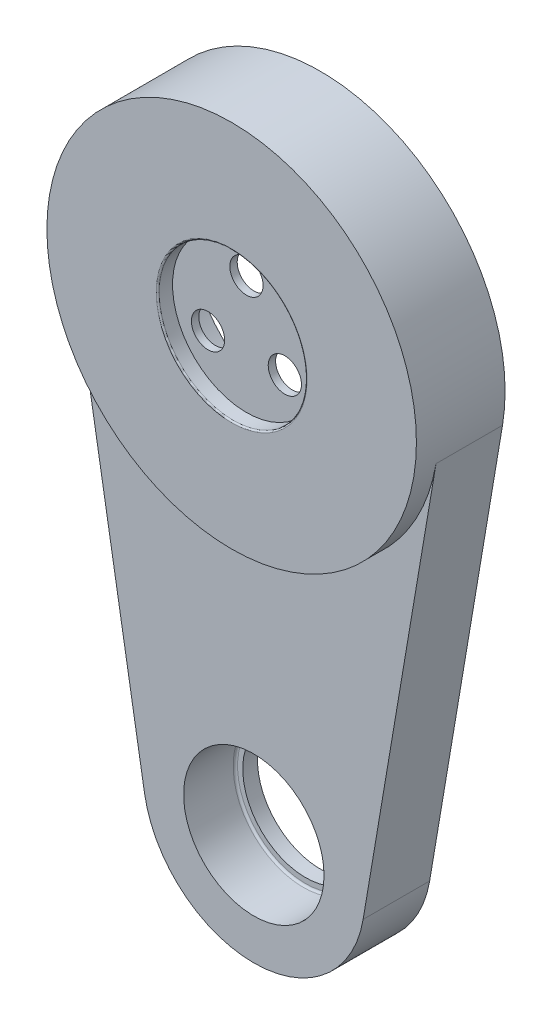
from build123d import *

# Parameters (mm, degrees)
SKETCH_2_R                   = 25
EXTRUDE_2_DEPTH              = 2
SKETCH_22_R                  = 10
CUT_EXTRUDE_1_DEPTH          = 2
FILLET_4_R                   = 0.2
SKETCH_54_R                  = 25
EXTRUDE_6_DEPTH              = 10
SKETCH_55_R                  = 18.5
CUT_EXTRUDE_2_DEPTH          = 8
HOLE_WIZARD_M4_1_D           = 4.5
HOLE_WIZARD_M4_1_CBORE_D     = 8
HOLE_WIZARD_M4_1_CBORE_DEPTH = 1
PATTERN_CIRCULAR_1_COUNT     = 3
SKETCH_59_R                  = 18.5
SKETCH_59_R_2                = 17.5
EXTRUDE_7_DEPTH              = 1
EXTRUDE_8_DEPTH              = 9
FILLET_6_R                   = 0.3
SKETCH_68_R                  = 9.5
CUT_EXTRUDE_7_DEPTH          = 7
SKETCH_69_R                  = 8.5
CUT_EXTRUDE_8_DEPTH          = 3
FILLET_7_R                   = 0.3


with BuildPart() as part:
    # 스케치2 → 보스-돌출2 (new body)
    with BuildSketch(Plane(origin=(0, 6, 0), x_dir=(1, 0, 0), z_dir=(0, 0, -1))):
        with Locations((0, 6)):
            Circle(SKETCH_2_R)
    extrude(amount=EXTRUDE_2_DEPTH)

    # 스케치22 → 컷-돌출1 (cut)
    with BuildSketch(Plane.XY):
        Circle(SKETCH_22_R)
    extrude(amount=-CUT_EXTRUDE_1_DEPTH, mode=Mode.SUBTRACT)

    # 필렛4
    fillet_4_edges = [part.edges().sort_by_distance(p)[0] for p in [
        (-10, 0, 0),
    ]]
    fillet(fillet_4_edges, radius=FILLET_4_R)

    # 스케치54 → 보스-돌출6 (add)
    with BuildSketch(Plane(origin=(0, 0, -2), x_dir=(-1, 0, 0), z_dir=(0, 0, -1))):
        Circle(SKETCH_54_R)
    extrude(amount=EXTRUDE_6_DEPTH)

    # 스케치55 → 컷-돌출2 (cut)
    with BuildSketch(Plane(origin=(0, 0, -12), x_dir=(-1, 0, 0), z_dir=(0, 0, -1))):
        Circle(SKETCH_55_R)
    extrude(amount=-CUT_EXTRUDE_2_DEPTH, mode=Mode.SUBTRACT)

    # M4 육각 소켓 머리 캡 나사용 카운터보어1 (through all)
    with Locations(Plane(origin=(0, 0, -4), x_dir=(-1, 0, 0), z_dir=(0, 0, -1))):
        with Locations((0, 6)):
            hole_wizard_m4_1 = CounterBoreHole(HOLE_WIZARD_M4_1_D / 2, HOLE_WIZARD_M4_1_CBORE_D / 2, HOLE_WIZARD_M4_1_CBORE_DEPTH)

    # 원형 패턴1: M4 육각 소켓 머리 캡 나사용 카운터보어1 ×3 about axis
    pattern_circular_1_axis = Axis((0, 0, 0), (0, 0, 1))
    for i in range(1, PATTERN_CIRCULAR_1_COUNT):
        add(hole_wizard_m4_1.rotate(pattern_circular_1_axis, i * 360 / PATTERN_CIRCULAR_1_COUNT), mode=Mode.SUBTRACT)

    # 스케치59 → 보스-돌출7 (add)
    with BuildSketch(Plane(origin=(0, 0, -4), x_dir=(-1, 0, 0), z_dir=(0, 0, -1))):
        Circle(SKETCH_59_R)
        Circle(SKETCH_59_R_2, mode=Mode.SUBTRACT)
    extrude(amount=EXTRUDE_7_DEPTH)

    # 스케치60 → 보스-돌출8 (add)
    with BuildSketch(Plane(origin=(0, 0, -12), x_dir=(-1, 0, 0), z_dir=(0, 0, -1))):
        with BuildLine():
            Line((-24.65033243, -4.166666667), (-14.790199458, -62.5))
            ThreePointArc((-14.790199458, -62.5), (0, -75), (14.790199458, -62.5))
            Line((14.790199458, -62.5), (24.65033243, -4.166666667))
            ThreePointArc((24.65033243, -4.166666667), (0, -25), (-24.65033243, -4.166666667))
        make_face()
    extrude(amount=-EXTRUDE_8_DEPTH)

    # 필렛6
    fillet_6_edges = [part.edges().sort_by_distance(p)[0] for p in [
        (18.5, 0, -5),
    ]]
    fillet(fillet_6_edges, radius=FILLET_6_R)

    # 스케치68 → 컷-돌출7 (cut)
    with BuildSketch(Plane.XY.offset(-3)):
        with Locations((0, -60)):
            Circle(SKETCH_68_R)
    extrude(amount=-CUT_EXTRUDE_7_DEPTH, mode=Mode.SUBTRACT)

    # 스케치69 → 컷-돌출8 (cut, through all)
    with BuildSketch(Plane.XY.offset(-10)):
        with Locations((0, -60)):
            Circle(SKETCH_69_R)
    extrude(amount=-CUT_EXTRUDE_8_DEPTH, mode=Mode.SUBTRACT)

    # 필렛7
    fillet_7_edges = [part.edges().sort_by_distance(p)[0] for p in [
        (-9.5, -60, -10),
    ]]
    fillet(fillet_7_edges, radius=FILLET_7_R)


solid = part.part
